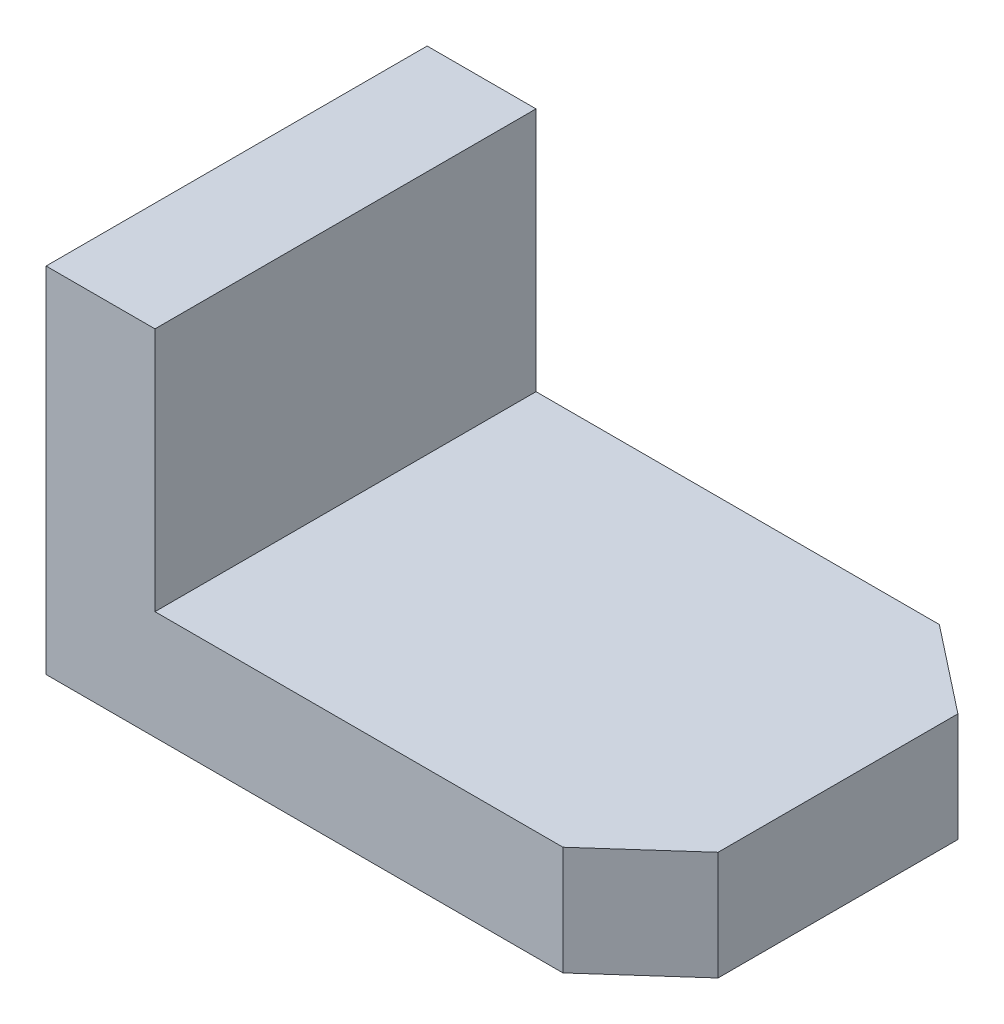
from build123d import *

# Parameters (mm, degrees)
SKETCH1_W           = 66
SKETCH1_H           = 42
BOSS_EXTRUDE1_DEPTH = 12
SKETCH2_W           = 12
SKETCH2_H           = 42
BOSS_EXTRUDE2_DEPTH = 26.995042498
CUT_EXTRUDE1_DEPTH  = 12


with BuildPart() as part:
    # Sketch1 → Boss-Extrude1 (new body)
    with BuildSketch(Plane(origin=(0, 0, 0), x_dir=(1, 0, 0), z_dir=(0, 1, 0))):
        Rectangle(SKETCH1_W, SKETCH1_H)
    extrude(amount=BOSS_EXTRUDE1_DEPTH)

    # Sketch2 → Boss-Extrude2 (add)
    with BuildSketch(Plane(origin=(0, 12, 0), x_dir=(1, 0, 0), z_dir=(0, 1, 0))):
        with Locations((-27, 0)):
            Rectangle(SKETCH2_W, SKETCH2_H)
    extrude(amount=BOSS_EXTRUDE2_DEPTH)

    # Sketch12 → Cut-Extrude1 (cut)
    with BuildSketch(Plane(origin=(0, 12, 0), x_dir=(1, 0, 0), z_dir=(0, 1, 0))):
        Polygon((33, -12.935780303), (33, -21), (23.965356614, -21), align=None)
        Polygon((33, 13.5), (33, 21), (23.455136658, 21), align=None)
    extrude(amount=-CUT_EXTRUDE1_DEPTH, mode=Mode.SUBTRACT)


solid = part.part
